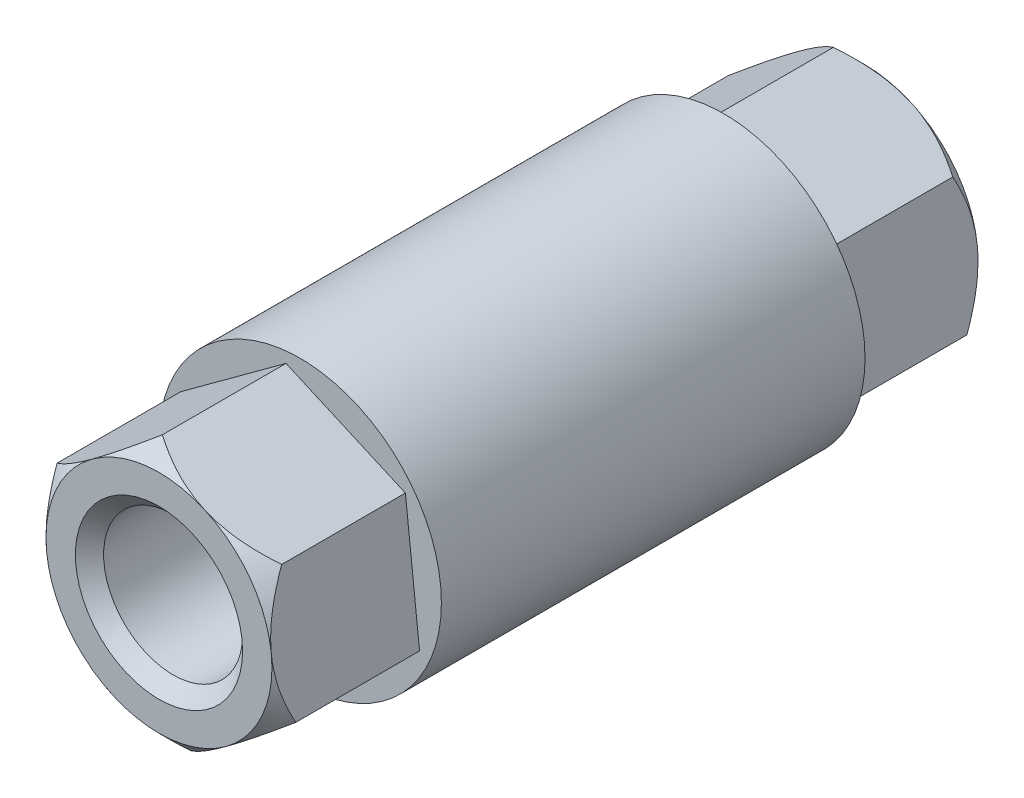
from build123d import *

# Parameters (mm, degrees)
SKETCH1_R               = 5
BOSS_EXTRUDE1_DEPTH     = 7.5
BOSS_EXTRUDE2_DEPTH     = 5
SKETCH3_R               = 2.46
CUT_EXTRUDE1_DEPTH      = 1
CUT_EXTRUDE1_DEPTH_BACK = 26
CHAMFER1_SIZE           = 0.5


with BuildPart() as part:
    # Sketch1 → Boss-Extrude1 (new body, symmetric)
    with BuildSketch(Plane.XY):
        Circle(SKETCH1_R)
    extrude(amount=BOSS_EXTRUDE1_DEPTH, both=True)

    # Sketch2 → Boss-Extrude2 (add)
    with BuildSketch(Plane.XY.offset(7.5)):
        Polygon((0.50159839, -4.59148477), (4.227141646, -1.861345437), (3.725543257, 2.730139333), (-0.50159839, 4.59148477), (-4.227141646, 1.861345437), (-3.725543257, -2.730139333), align=None)
    boss_extrude2 = extrude(amount=BOSS_EXTRUDE2_DEPTH)

    # Mirror1: Boss-Extrude2 across plane
    add(boss_extrude2.mirror(Plane.XY))

    # Sketch3 → Cut-Extrude1 (cut, two sides)
    with BuildSketch(Plane.XY.offset(12.5)) as cut_extrude1_sk:
        Circle(SKETCH3_R)
    extrude(amount=CUT_EXTRUDE1_DEPTH, mode=Mode.SUBTRACT)
    extrude(cut_extrude1_sk.sketch, amount=-CUT_EXTRUDE1_DEPTH_BACK, mode=Mode.SUBTRACT)

    # Chamfer1
    chamfer1_edges = [part.edges().sort_by_distance(p)[0] for p in [
        (-2.46, 0, 12.5),
        (-2.46, 0, -12.5),
    ]]
    chamfer(chamfer1_edges, length=CHAMFER1_SIZE)

    # Sketch8 → Cut-Revolve3 (revolve, cut)
    with BuildSketch(Plane(origin=(0, 0, 0), x_dir=(-0.915203013, 0.402993108, 0), z_dir=(-0.402993108, -0.915203013, 0))):
        Polygon((4, 12.5), (4.618802154, 12.5), (4.618802154, 11.881197846), align=None)
    cut_revolve3 = revolve(axis=Axis((0, 0, -12), (0, 0, 1)), mode=Mode.SUBTRACT)

    # Mirror2: Cut-Revolve3 across plane
    add(cut_revolve3.mirror(Plane.XY), mode=Mode.SUBTRACT)


solid = part.part
